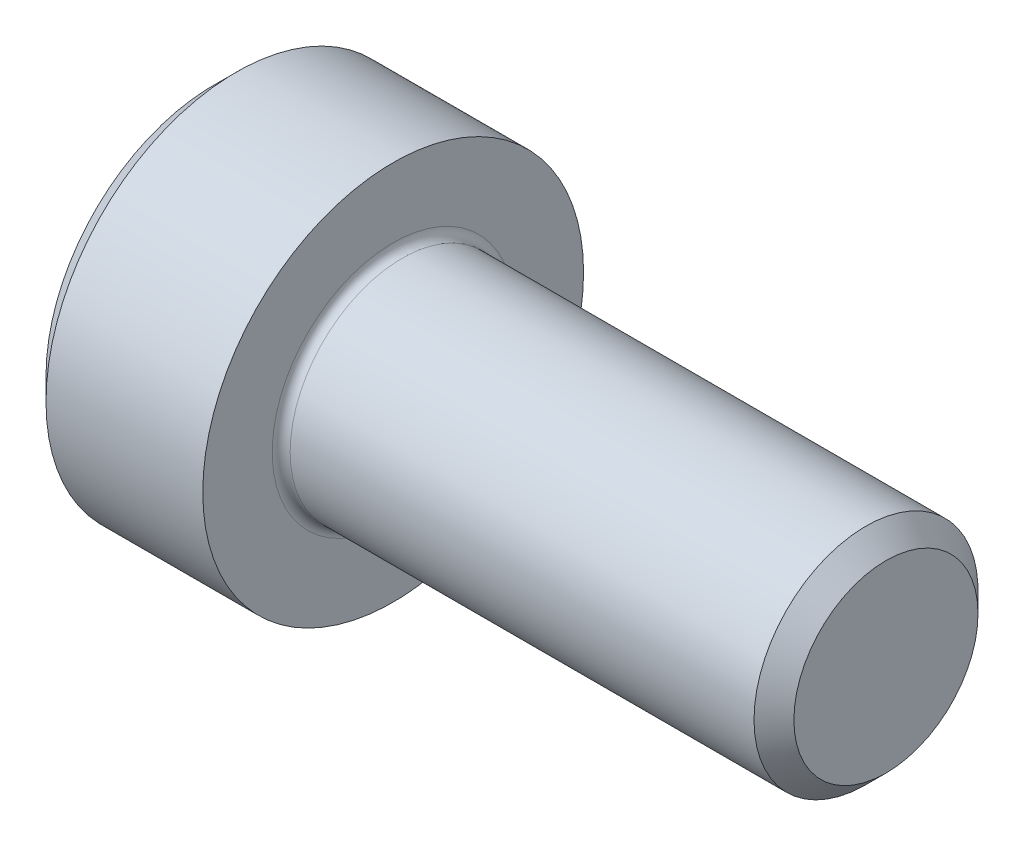
from build123d import *

# Parameters (mm, degrees)
FILLET1_R   = 0.2
HEX_2_DEPTH = 2.5


with BuildPart() as part:
    # BodySke → Base-Revolve (revolve)
    with BuildSketch(Plane.XY):
        Polygon((0, 0), (0, 3.75), (0.5, 4.25), (4, 4.25), (4, 2.5), (14.555, 2.5), (15, 2.055), (15, 0), align=None)
    revolve(axis=Axis((-31.75, 0, 0), (1, 0, 0)))

    # Fillet1
    fillet1_edges = [part.edges().sort_by_distance(p)[0] for p in [
        (4, -2.5, 0),
    ]]
    fillet(fillet1_edges, radius=FILLET1_R)

    # Sketch2 → Hex-PreBroach (revolve, cut)
    with BuildSketch(Plane.XY):
        Polygon((0, 2.042), (2.5, 2.042), (3.67894925, 0), (0, 0), align=None)
    revolve(axis=Axis((0, 0, 0), (1, 0, 0)), mode=Mode.SUBTRACT)

    # Sketch3 → Hex 2 (cut)
    with BuildSketch(Plane(origin=(0, 0, 0), x_dir=(0, 0.5, 0.866025404), z_dir=(-1, 0, 0))):
        Polygon((1.17894925, 2.042), (-1.17894925, 2.042), (-2.357898499, 0), (-1.17894925, -2.042), (1.17894925, -2.042), (2.357898499, 0), align=None)
    extrude(amount=-HEX_2_DEPTH, mode=Mode.SUBTRACT)


solid = part.part
